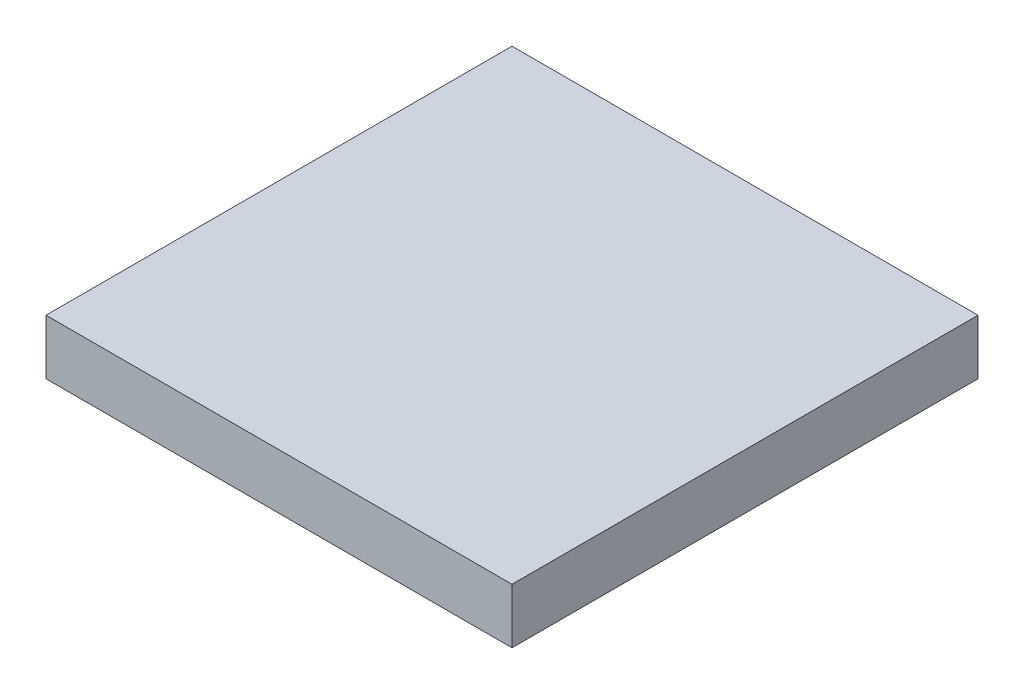
from build123d import *

# Parameters (mm, degrees)
SKETCH_1_W      = 12.7
SKETCH_1_H      = 12.7
EXTRUDE_1_DEPTH = 1.5


with BuildPart() as part:
    # 草图1 → 凸台-拉伸1 (new body)
    with BuildSketch(Plane(origin=(0, 0, 0), x_dir=(1, 0, 0), z_dir=(0, 1, 0))):
        Rectangle(SKETCH_1_W, SKETCH_1_H)
    extrude(amount=EXTRUDE_1_DEPTH)


solid = part.part
